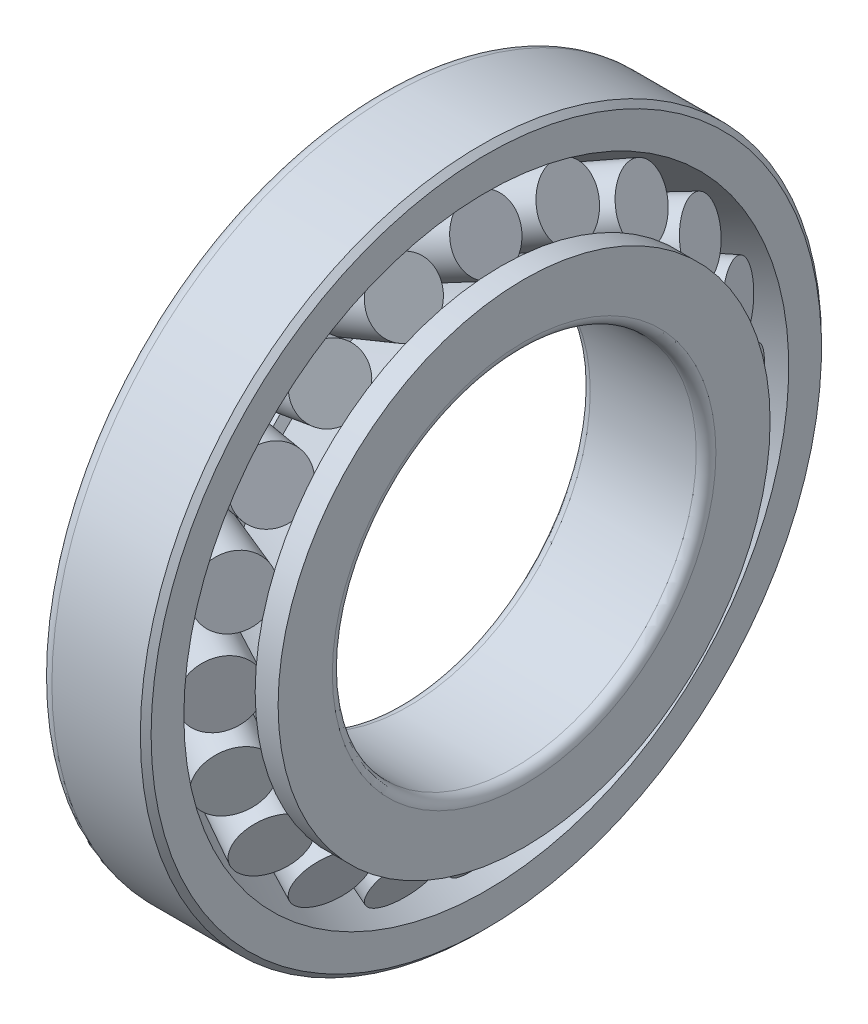
from build123d import *

# Parameters (mm, degrees)
CIRPATTERN3_COUNT = 20
SCALE1_SCALE      = 0.316666667
SCALE3_SCALE      = 1.1


with BuildPart() as part:
    # Sketch1 → Revolve1 (revolve)
    with BuildSketch(Plane.XY, mode=Mode.PRIVATE) as revolve1_sk:
        with BuildLine():
            Line((-56.371530242, 75), (-23.728263205, 92.356732964))
            Line((-23.728263205, 92.356732964), (-23.728263205, 102.356732964))
            Line((-23.728263205, 102.356732964), (-25.371530242, 104))
            Line((-25.371530242, 104), (-52.371530242, 104))
            ThreePointArc((-52.371530242, 104), (-55.199957367, 102.828427125), (-56.371530242, 100))
            Line((-56.371530242, 100), (-56.371530242, 75))
        make_face()
    revolve(revolve1_sk.sketch.rotate(Axis((0, 0, 0), (1, 0, 0)), 90), axis=Axis((0, 0, 0), (1, 0, 0)))


with BuildPart() as body_2:
    # Sketch2 → Revolve2 (revolve)
    with BuildSketch(Plane.XY, mode=Mode.PRIVATE) as revolve2_sk:
        Polygon((-51.528215431, 77.575236166), (-46.833499803, 68.745760237), (-23.876862389, 80.952020869), (-28.571578016, 89.781496798), align=None)
    revolve(revolve2_sk.sketch.rotate(Axis((-46.833499803, 68.745760237, 0), (0.882947592858924, 0.46947156278589636, 0)), 180), axis=Axis((-46.833499803, 68.745760237, 0), (0.882947592858924, 0.46947156278589636, 0)))


with BuildPart() as body_3:
    # Sketch4 → Revolve6 (revolve)
    with BuildSketch(Plane.XY, mode=Mode.PRIVATE) as revolve6_sk:
        with BuildLine():
            Line((-43.547198863, 62.565127087), (-42.138784175, 59.916284308))
            Line((-42.138784175, 59.916284308), (-19.182146761, 72.122544941))
            Line((-19.182146761, 72.122544941), (-19.182146761, 75.122544941))
            Line((-19.182146761, 75.122544941), (-12.182146761, 75.122544941))
            Line((-12.182146761, 75.122544941), (-12.182146761, 58.565127087))
            ThreePointArc((-12.182146761, 58.565127087), (-13.060826417, 56.443806743), (-15.182146761, 55.565127087))
            Line((-15.182146761, 55.565127087), (-47.547198863, 55.565127087))
            ThreePointArc((-47.547198863, 55.565127087), (-49.668519207, 56.443806743), (-50.547198863, 58.565127087))
            Line((-50.547198863, 58.565127087), (-50.547198863, 62.565127087))
            Line((-50.547198863, 62.565127087), (-43.547198863, 62.565127087))
        make_face()
    revolve(revolve6_sk.sketch.rotate(Axis((0, 0, 0), (1, 0, 0)), 90), axis=Axis((0, 0, 0), (1, 0, 0)))


with BuildPart() as cirpattern3_1:
    # CirPattern3: pattern copy
    add(body_2.part.rotate(Axis((0, 0, 0), (1, 0, 0)), 1 * 360 / CIRPATTERN3_COUNT))


with BuildPart() as cirpattern3_2:
    # CirPattern3: pattern copy
    add(body_2.part.rotate(Axis((0, 0, 0), (1, 0, 0)), 2 * 360 / CIRPATTERN3_COUNT))


with BuildPart() as cirpattern3_3:
    # CirPattern3: pattern copy
    add(body_2.part.rotate(Axis((0, 0, 0), (1, 0, 0)), 3 * 360 / CIRPATTERN3_COUNT))


with BuildPart() as cirpattern3_4:
    # CirPattern3: pattern copy
    add(body_2.part.rotate(Axis((0, 0, 0), (1, 0, 0)), 4 * 360 / CIRPATTERN3_COUNT))


with BuildPart() as cirpattern3_5:
    # CirPattern3: pattern copy
    add(body_2.part.rotate(Axis((0, 0, 0), (1, 0, 0)), 5 * 360 / CIRPATTERN3_COUNT))


with BuildPart() as cirpattern3_6:
    # CirPattern3: pattern copy
    add(body_2.part.rotate(Axis((0, 0, 0), (1, 0, 0)), 6 * 360 / CIRPATTERN3_COUNT))


with BuildPart() as cirpattern3_7:
    # CirPattern3: pattern copy
    add(body_2.part.rotate(Axis((0, 0, 0), (1, 0, 0)), 7 * 360 / CIRPATTERN3_COUNT))


with BuildPart() as cirpattern3_8:
    # CirPattern3: pattern copy
    add(body_2.part.rotate(Axis((0, 0, 0), (1, 0, 0)), 8 * 360 / CIRPATTERN3_COUNT))


with BuildPart() as cirpattern3_9:
    # CirPattern3: pattern copy
    add(body_2.part.rotate(Axis((0, 0, 0), (1, 0, 0)), 9 * 360 / CIRPATTERN3_COUNT))


with BuildPart() as cirpattern3_10:
    # CirPattern3: pattern copy
    add(body_2.part.rotate(Axis((0, 0, 0), (1, 0, 0)), 10 * 360 / CIRPATTERN3_COUNT))


with BuildPart() as cirpattern3_11:
    # CirPattern3: pattern copy
    add(body_2.part.rotate(Axis((0, 0, 0), (1, 0, 0)), 11 * 360 / CIRPATTERN3_COUNT))


with BuildPart() as cirpattern3_12:
    # CirPattern3: pattern copy
    add(body_2.part.rotate(Axis((0, 0, 0), (1, 0, 0)), 12 * 360 / CIRPATTERN3_COUNT))


with BuildPart() as cirpattern3_13:
    # CirPattern3: pattern copy
    add(body_2.part.rotate(Axis((0, 0, 0), (1, 0, 0)), 13 * 360 / CIRPATTERN3_COUNT))


with BuildPart() as cirpattern3_14:
    # CirPattern3: pattern copy
    add(body_2.part.rotate(Axis((0, 0, 0), (1, 0, 0)), 14 * 360 / CIRPATTERN3_COUNT))


with BuildPart() as cirpattern3_15:
    # CirPattern3: pattern copy
    add(body_2.part.rotate(Axis((0, 0, 0), (1, 0, 0)), 15 * 360 / CIRPATTERN3_COUNT))


with BuildPart() as cirpattern3_16:
    # CirPattern3: pattern copy
    add(body_2.part.rotate(Axis((0, 0, 0), (1, 0, 0)), 16 * 360 / CIRPATTERN3_COUNT))


with BuildPart() as cirpattern3_17:
    # CirPattern3: pattern copy
    add(body_2.part.rotate(Axis((0, 0, 0), (1, 0, 0)), 17 * 360 / CIRPATTERN3_COUNT))


with BuildPart() as cirpattern3_18:
    # CirPattern3: pattern copy
    add(body_2.part.rotate(Axis((0, 0, 0), (1, 0, 0)), 18 * 360 / CIRPATTERN3_COUNT))


with BuildPart() as cirpattern3_19:
    # CirPattern3: pattern copy
    add(body_2.part.rotate(Axis((0, 0, 0), (1, 0, 0)), 19 * 360 / CIRPATTERN3_COUNT))


with BuildPart() as cirpattern3_17_1:
    # Scale1: scaled about (0, 0, 0)
    add(cirpattern3_17.part.scale(SCALE1_SCALE))


with BuildPart() as cirpattern3_19_1:
    # Scale1: scaled about (0, 0, 0)
    add(cirpattern3_19.part.scale(SCALE1_SCALE))


with BuildPart() as body_2_1:
    # Scale1: scaled about (0, 0, 0)
    add(body_2.part.scale(SCALE1_SCALE))


with BuildPart() as cirpattern3_1_1:
    # Scale1: scaled about (0, 0, 0)
    add(cirpattern3_1.part.scale(SCALE1_SCALE))


with BuildPart() as cirpattern3_2_1:
    # Scale1: scaled about (0, 0, 0)
    add(cirpattern3_2.part.scale(SCALE1_SCALE))


with BuildPart() as cirpattern3_3_1:
    # Scale1: scaled about (0, 0, 0)
    add(cirpattern3_3.part.scale(SCALE1_SCALE))


with BuildPart() as cirpattern3_4_1:
    # Scale1: scaled about (0, 0, 0)
    add(cirpattern3_4.part.scale(SCALE1_SCALE))


with BuildPart() as cirpattern3_5_1:
    # Scale1: scaled about (0, 0, 0)
    add(cirpattern3_5.part.scale(SCALE1_SCALE))


with BuildPart() as cirpattern3_6_1:
    # Scale1: scaled about (0, 0, 0)
    add(cirpattern3_6.part.scale(SCALE1_SCALE))


with BuildPart() as cirpattern3_7_1:
    # Scale1: scaled about (0, 0, 0)
    add(cirpattern3_7.part.scale(SCALE1_SCALE))


with BuildPart() as cirpattern3_8_1:
    # Scale1: scaled about (0, 0, 0)
    add(cirpattern3_8.part.scale(SCALE1_SCALE))


with BuildPart() as cirpattern3_9_1:
    # Scale1: scaled about (0, 0, 0)
    add(cirpattern3_9.part.scale(SCALE1_SCALE))


with BuildPart() as cirpattern3_10_1:
    # Scale1: scaled about (0, 0, 0)
    add(cirpattern3_10.part.scale(SCALE1_SCALE))


with BuildPart() as cirpattern3_11_1:
    # Scale1: scaled about (0, 0, 0)
    add(cirpattern3_11.part.scale(SCALE1_SCALE))


with BuildPart() as cirpattern3_12_1:
    # Scale1: scaled about (0, 0, 0)
    add(cirpattern3_12.part.scale(SCALE1_SCALE))


with BuildPart() as cirpattern3_13_1:
    # Scale1: scaled about (0, 0, 0)
    add(cirpattern3_13.part.scale(SCALE1_SCALE))


with BuildPart() as cirpattern3_14_1:
    # Scale1: scaled about (0, 0, 0)
    add(cirpattern3_14.part.scale(SCALE1_SCALE))


with BuildPart() as cirpattern3_15_1:
    # Scale1: scaled about (0, 0, 0)
    add(cirpattern3_15.part.scale(SCALE1_SCALE))


with BuildPart() as cirpattern3_16_1:
    # Scale1: scaled about (0, 0, 0)
    add(cirpattern3_16.part.scale(SCALE1_SCALE))


with BuildPart() as part_1:
    # Scale1: scaled about (0, 0, 0)
    add(part.part.scale(SCALE1_SCALE))


with BuildPart() as cirpattern3_18_1:
    # Scale1: scaled about (0, 0, 0)
    add(cirpattern3_18.part.scale(SCALE1_SCALE))


with BuildPart() as body_3_1:
    # Scale1: scaled about (0, 0, 0)
    add(body_3.part.scale(SCALE1_SCALE))


with BuildPart() as part_2:
    # Scale3: scaled about (0, 0, 0)
    add(part_1.part.scale(SCALE3_SCALE))


with BuildPart() as body_3_2:
    # Scale3: scaled about (0, 0, 0)
    add(body_3_1.part.scale(SCALE3_SCALE))


with BuildPart() as cirpattern3_11_2:
    # Scale3: scaled about (0, 0, 0)
    add(cirpattern3_11_1.part.scale(SCALE3_SCALE))


with BuildPart() as cirpattern3_10_2:
    # Scale3: scaled about (0, 0, 0)
    add(cirpattern3_10_1.part.scale(SCALE3_SCALE))


with BuildPart() as cirpattern3_9_2:
    # Scale3: scaled about (0, 0, 0)
    add(cirpattern3_9_1.part.scale(SCALE3_SCALE))


with BuildPart() as cirpattern3_8_2:
    # Scale3: scaled about (0, 0, 0)
    add(cirpattern3_8_1.part.scale(SCALE3_SCALE))


with BuildPart() as cirpattern3_12_2:
    # Scale3: scaled about (0, 0, 0)
    add(cirpattern3_12_1.part.scale(SCALE3_SCALE))


with BuildPart() as cirpattern3_13_2:
    # Scale3: scaled about (0, 0, 0)
    add(cirpattern3_13_1.part.scale(SCALE3_SCALE))


with BuildPart() as cirpattern3_14_2:
    # Scale3: scaled about (0, 0, 0)
    add(cirpattern3_14_1.part.scale(SCALE3_SCALE))


with BuildPart() as cirpattern3_15_2:
    # Scale3: scaled about (0, 0, 0)
    add(cirpattern3_15_1.part.scale(SCALE3_SCALE))


with BuildPart() as cirpattern3_16_2:
    # Scale3: scaled about (0, 0, 0)
    add(cirpattern3_16_1.part.scale(SCALE3_SCALE))


with BuildPart() as cirpattern3_17_2:
    # Scale3: scaled about (0, 0, 0)
    add(cirpattern3_17_1.part.scale(SCALE3_SCALE))


with BuildPart() as cirpattern3_18_2:
    # Scale3: scaled about (0, 0, 0)
    add(cirpattern3_18_1.part.scale(SCALE3_SCALE))


with BuildPart() as cirpattern3_19_2:
    # Scale3: scaled about (0, 0, 0)
    add(cirpattern3_19_1.part.scale(SCALE3_SCALE))


with BuildPart() as body_2_2:
    # Scale3: scaled about (0, 0, 0)
    add(body_2_1.part.scale(SCALE3_SCALE))


with BuildPart() as cirpattern3_1_2:
    # Scale3: scaled about (0, 0, 0)
    add(cirpattern3_1_1.part.scale(SCALE3_SCALE))


with BuildPart() as cirpattern3_2_2:
    # Scale3: scaled about (0, 0, 0)
    add(cirpattern3_2_1.part.scale(SCALE3_SCALE))


with BuildPart() as cirpattern3_3_2:
    # Scale3: scaled about (0, 0, 0)
    add(cirpattern3_3_1.part.scale(SCALE3_SCALE))


with BuildPart() as cirpattern3_4_2:
    # Scale3: scaled about (0, 0, 0)
    add(cirpattern3_4_1.part.scale(SCALE3_SCALE))


with BuildPart() as cirpattern3_5_2:
    # Scale3: scaled about (0, 0, 0)
    add(cirpattern3_5_1.part.scale(SCALE3_SCALE))


with BuildPart() as cirpattern3_6_2:
    # Scale3: scaled about (0, 0, 0)
    add(cirpattern3_6_1.part.scale(SCALE3_SCALE))


with BuildPart() as cirpattern3_7_2:
    # Scale3: scaled about (0, 0, 0)
    add(cirpattern3_7_1.part.scale(SCALE3_SCALE))


solid = Compound([part_2.part, body_3_2.part, cirpattern3_11_2.part, cirpattern3_10_2.part, cirpattern3_9_2.part, cirpattern3_8_2.part, cirpattern3_12_2.part, cirpattern3_13_2.part, cirpattern3_14_2.part, cirpattern3_15_2.part, cirpattern3_16_2.part, cirpattern3_17_2.part, cirpattern3_18_2.part, cirpattern3_19_2.part, body_2_2.part, cirpattern3_1_2.part, cirpattern3_2_2.part, cirpattern3_3_2.part, cirpattern3_4_2.part, cirpattern3_5_2.part, cirpattern3_6_2.part, cirpattern3_7_2.part])
